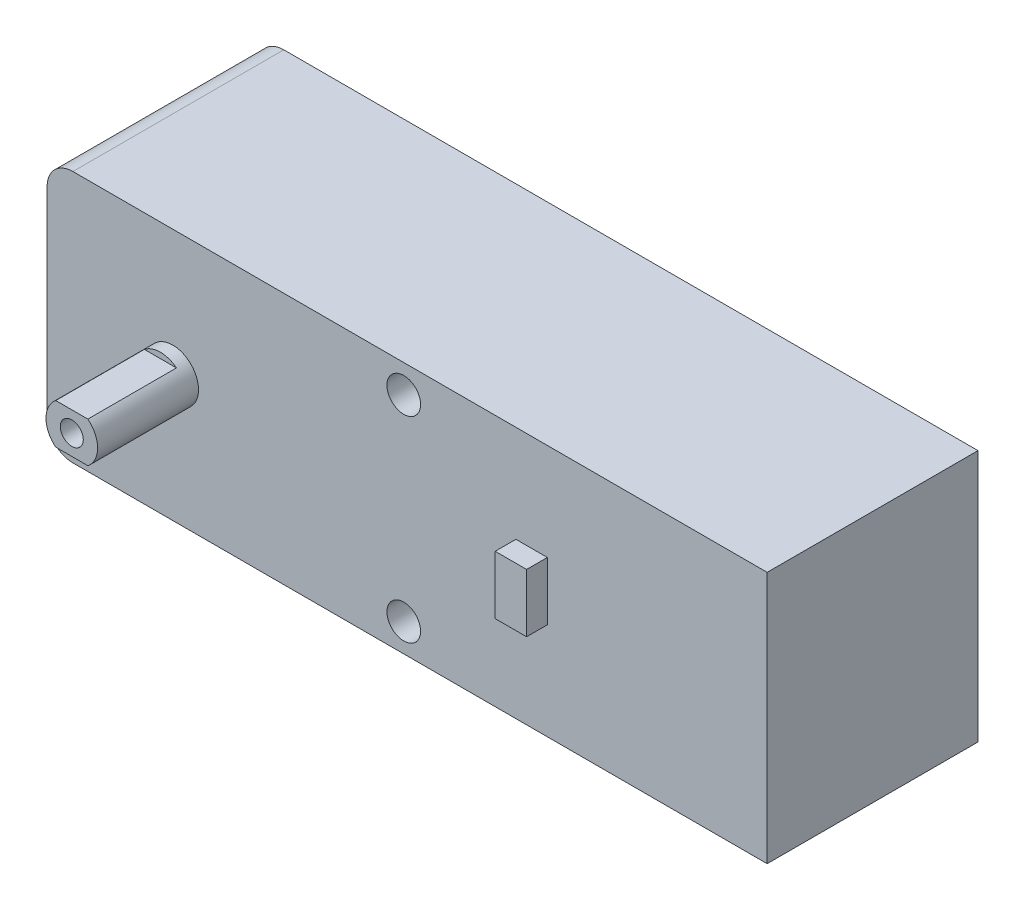
from build123d import *

# Parameters (mm, degrees)
ESBO_O1_W                = 64.2
ESBO_O1_H                = 22.5
RESSALTO_EXTRUS_O1_DEPTH = 9.4
ESBO_O2_R                = 2.3
RESSALTO_EXTRUS_O2_DEPTH = 9
CORTE_EXTRUS_O1_DEPTH    = 7.9
ESBO_O4_R                = 1.5
CORTE_EXTRUS_O2_DEPTH    = 19.8
FILETE1_R                = 2.3
ESBO_O5_W                = 2.8
ESBO_O5_H                = 5.2
RESSALTO_EXTRUS_O3_DEPTH = 1.85


with BuildPart() as part:
    # Esboço1 → Ressalto-extrusão1 (new body, symmetric)
    with BuildSketch(Plane.XY):
        with Locations((32.1, 11.25)):
            Rectangle(ESBO_O1_W, ESBO_O1_H)
    extrude(amount=RESSALTO_EXTRUS_O1_DEPTH, both=True)

    # Esboço2 → Ressalto-extrusão2 (add)
    with BuildSketch(Plane.XY.offset(9.4)):
        with Locations((11.2, 11.25)):
            Circle(ESBO_O2_R)
    ressalto_extrus_o2 = extrude(amount=RESSALTO_EXTRUS_O2_DEPTH)

    # Esboço3 → Corte-extrusão1 (cut)
    with BuildSketch(Plane.XY.offset(18.4)):
        with BuildLine():
            Line((9.768217894, 13.05), (12.631782106, 13.05))
            ThreePointArc((12.631782106, 13.05), (11.2, 13.55), (9.768217894, 13.05))
        make_face()
        with BuildLine():
            Line((12.631782106, 9.45), (9.768217894, 9.45))
            ThreePointArc((9.768217894, 9.45), (11.2, 8.95), (12.631782106, 9.45))
        make_face()
    corte_extrus_o1 = extrude(amount=-CORTE_EXTRUS_O1_DEPTH, mode=Mode.SUBTRACT)

    # Esboço4 → Corte-extrusão2 (cut, through all)
    with BuildSketch(Plane.XY.offset(9.4)):
        with Locations((31.8, 20)):
            Circle(ESBO_O4_R)
        with Locations((31.8, 2.5)):
            Circle(ESBO_O4_R)
    extrude(amount=-CORTE_EXTRUS_O2_DEPTH, mode=Mode.SUBTRACT)

    # Esboço6 → Furo roscado de M2.51 (revolve, cut)
    with BuildSketch(Plane(origin=(11.2, 11.25, 18.4), x_dir=(0, -1, 0), z_dir=(1, 0, 0))):
        Polygon((0, 0), (0, 7.865882135), (1.025, 7.25), (1.025, 0), align=None)
    furo_roscado_de_m2_51 = revolve(axis=Axis((11.2, 11.25, 24.75), (0, 0, -1)), mode=Mode.SUBTRACT)

    # Espelhar1: Ressalto-extrusão2, Corte-extrusão1, Furo roscado de M2.51 across plane
    add(ressalto_extrus_o2.mirror(Plane.XY))
    add(corte_extrus_o1.mirror(Plane.XY), mode=Mode.SUBTRACT)
    add(furo_roscado_de_m2_51.mirror(Plane.XY), mode=Mode.SUBTRACT)

    # Filete1
    filete1_edges = [part.edges().sort_by_distance(p)[0] for p in [
        (0, 22.5, 0),
        (0, 0, 0),
    ]]
    fillet(filete1_edges, radius=FILETE1_R)

    # Esboço5 → Ressalto-extrusão3 (add)
    with BuildSketch(Plane.XY.offset(9.4)):
        with Locations((43.2, 11.25)):
            Rectangle(ESBO_O5_W, ESBO_O5_H)
    extrude(amount=RESSALTO_EXTRUS_O3_DEPTH)


solid = part.part
